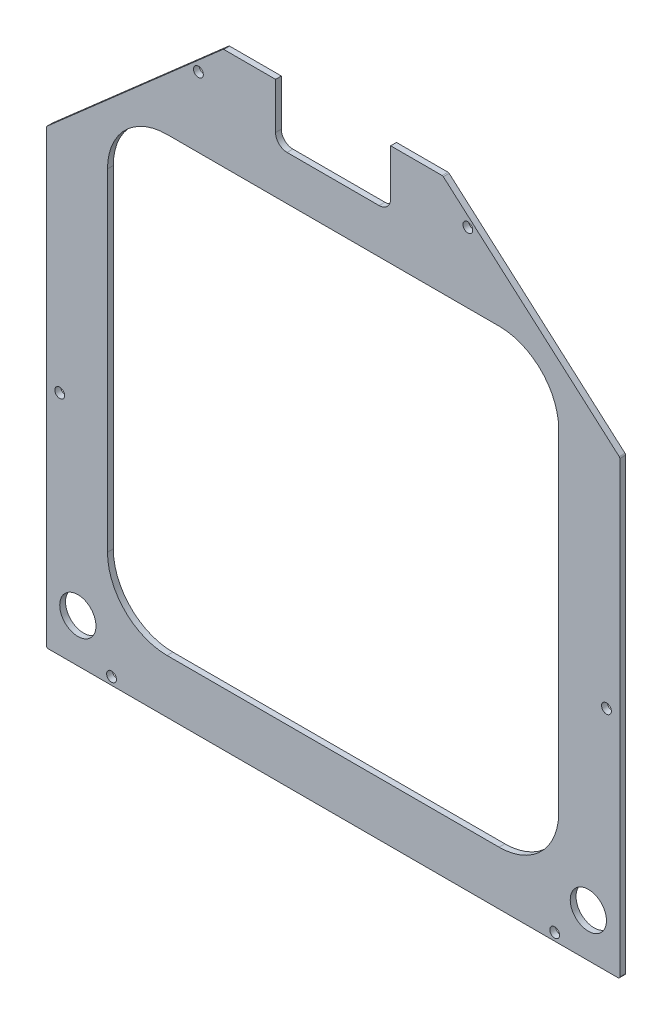
from build123d import *

# Parameters (mm, degrees)
BOSS_EXTRUDE1_DEPTH        = 1.6002
F_2_CLEARANCE_HOLE1_D      = 2.7051
SKETCH8_W                  = 31.75
SKETCH8_H                  = 15.875
CUT_EXTRUDE3_DEPTH         = 2.6002
FILLET1_R                  = 3.175
F_10_0_10_DIAMETER_HOLE1_D = 10


with BuildPart() as part:
    # Sketch2 → Boss-Extrude1 (new body)
    with BuildSketch(Plane.XY.offset(1.5875)):
        with BuildLine():
            Line((70.711408136, 21.697450137), (10.568555904, 21.697450137))
            ThreePointArc((10.568555904, 21.697450137), (10.389483229, 21.664841533), (10.233399988, 21.571201994))
            Line((10.233399988, 21.571201994), (-38.276423867, -21.017595986))
            ThreePointArc((-38.276423867, -21.017595986), (-38.404043925, -21.189818895), (-38.449267951, -21.399347884))
            Line((-38.449267951, -21.399347884), (-38.449267951, -145.180549937))
            ThreePointArc((-38.449267951, -145.180549937), (-38.300478171, -145.539760241), (-37.941267867, -145.688549937))
            Line((-37.941267867, -145.688549937), (119.221232133, -145.688549937))
            ThreePointArc((119.221232133, -145.688549937), (119.580442454, -145.53976015), (119.729232133, -145.18054983))
            Line((119.729232133, -145.18054983), (119.729232133, -21.399347777))
            ThreePointArc((119.729232133, -21.399347777), (119.684008101, -21.189818753), (119.556387965, -21.017595879))
            Line((119.556387965, -21.017595879), (71.046564052, 21.571202036))
            ThreePointArc((71.046564052, 21.571202036), (70.890480797, 21.664841536), (70.711408136, 21.697450137))
        make_face()
        with BuildLine():
            Line((102.869982113, -114.451909481), (102.869982113, -22.874190224))
            ThreePointArc((102.869982113, -22.874190224), (98.05448357, -11.248548333), (86.428841679, -6.433049852))
            Line((86.428841679, -6.433049852), (-5.148877578, -6.433049852))
            ThreePointArc((-5.148877578, -6.433049852), (-16.774519469, -11.248548395), (-21.59001795, -22.874190286))
            Line((-21.59001795, -22.874190286), (-21.59001795, -114.451909543))
            ThreePointArc((-21.59001795, -114.451909543), (-16.774519407, -126.077551434), (-5.148877516, -130.893049915))
            Line((-5.148877516, -130.893049915), (86.428841741, -130.893049915))
            ThreePointArc((86.428841741, -130.893049915), (98.054483632, -126.077551372), (102.869982113, -114.451909481))
        make_face(mode=Mode.SUBTRACT)
    extrude(amount=BOSS_EXTRUDE1_DEPTH)

    # #2 Clearance Hole1 (through all)
    with Locations(Plane.XY.offset(3.1877)):
        with Locations((3.4816648, 12.855075079), (77.798299252, 12.855075129), (-34.763097208, -82.95054975), (116.04306139, -82.950549647), (101.758732132, -143.593049842), (-20.478767868, -143.593049925)):
            Hole(F_2_CLEARANCE_HOLE1_D / 2)

    # Sketch8 → Cut-Extrude3 (cut, through all)
    with BuildSketch(Plane.XY.offset(3.1877)):
        with Locations((40.63998202, 13.759950137)):
            Rectangle(SKETCH8_W, SKETCH8_H)
    extrude(amount=-CUT_EXTRUDE3_DEPTH, mode=Mode.SUBTRACT)

    # Fillet1
    fillet1_edges = [part.edges().sort_by_distance(p)[0] for p in [
        (56.51498202, 5.822450137, 2.3876),
        (24.76498202, 5.822450137, 2.3876),
    ]]
    fillet(fillet1_edges, radius=FILLET1_R)

    # Ø10.0 (10) Diameter Hole1 (through all)
    with Locations(Plane(origin=(0, 0, 1.5875), x_dir=(-1, 0, 0), z_dir=(0, 0, -1))):
        with Locations((-111.045602766, -133.661649696), (29.765638361, -133.661649887)):
            Hole(F_10_0_10_DIAMETER_HOLE1_D / 2)


solid = part.part
